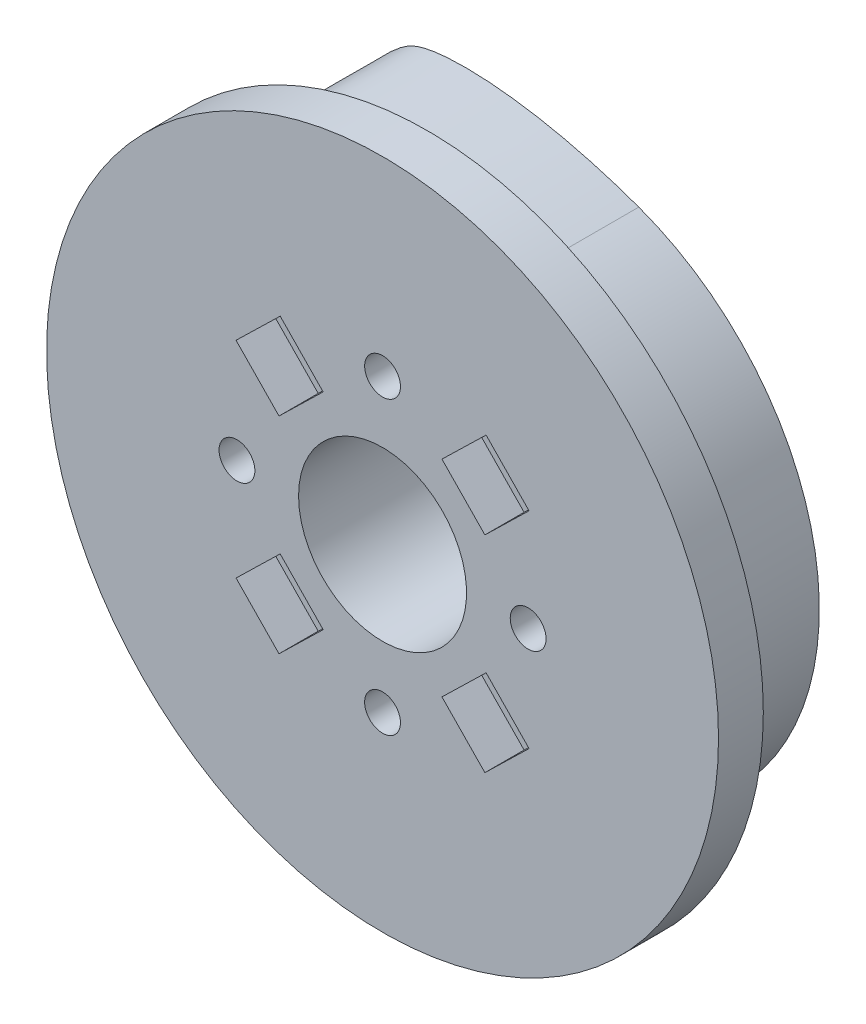
from build123d import *

# Parameters (mm, degrees)
SKETCH1_R           = 21
SKETCH1_R_2         = 2.85
SKETCH1_R_3         = 1.6
BOSS_EXTRUDE1_DEPTH = 10.5
SKETCH2_R           = 24.5
SKETCH2_R_2         = 21
BOSS_EXTRUDE3_DEPTH = 10.5
SKETCH4_R           = 30
SKETCH4_R_2         = 1.6
BOSS_EXTRUDE5_DEPTH = 4
SKETCH3_R           = 21
SKETCH3_R_2         = 1.6
BOSS_EXTRUDE4_DEPTH = 0.5
SKETCH6_W           = 5.5
SKETCH6_H           = 5.5
CUT_EXTRUDE2_DEPTH  = 3.5
SKETCH7_R           = 1.6
CUT_EXTRUDE3_DEPTH  = 46.000000133
SKETCH7_3_R         = 1.6
CUT_EXTRUDE4_DEPTH  = 3.5
SKETCH8_R           = 7.5
CUT_EXTRUDE5_DEPTH  = 46.000000133


with BuildPart() as part:
    # Sketch1 → Boss-Extrude1 (new body)
    with BuildSketch(Plane(origin=(0, 0, 0), x_dir=(0, 1, 0), z_dir=(0, 0, 1))):
        with Locations(Location((0, 0, 0), (0, 0, 90))):
            Circle(SKETCH1_R)
        with Locations((-13, 0)):
            Circle(SKETCH1_R_2, mode=Mode.SUBTRACT)
        with Locations((0, -13)):
            Circle(SKETCH1_R_2, mode=Mode.SUBTRACT)
        with Locations((13, 0)):
            Circle(SKETCH1_R_2, mode=Mode.SUBTRACT)
        with Locations((0, 13)):
            Circle(SKETCH1_R_2, mode=Mode.SUBTRACT)
        with Locations((-13, 0)):
            Circle(SKETCH1_R_2)
        with Locations(Location((-13, 0, 0), (0, 0, 90))):
            Circle(SKETCH1_R_3, mode=Mode.SUBTRACT)
        with Locations((0, 13)):
            Circle(SKETCH1_R_2)
        with Locations(Location((0, 13, 0), (0, 0, 90))):
            Circle(SKETCH1_R_3, mode=Mode.SUBTRACT)
        with Locations((13, 0)):
            Circle(SKETCH1_R_2)
        with Locations(Location((13, 0, 0), (0, 0, 90))):
            Circle(SKETCH1_R_3, mode=Mode.SUBTRACT)
        with Locations((0, -13)):
            Circle(SKETCH1_R_2)
        with Locations(Location((0, -13, 0), (0, 0, 90))):
            Circle(SKETCH1_R_3, mode=Mode.SUBTRACT)
    extrude(amount=BOSS_EXTRUDE1_DEPTH)

    # Sketch2 → Boss-Extrude3 (add)
    with BuildSketch(Plane(origin=(0, 0, 0), x_dir=(1, 0, 0), z_dir=(0, 0, -1))):
        Circle(SKETCH2_R)
        Circle(SKETCH2_R_2, mode=Mode.SUBTRACT)
        with BuildLine():
            ThreePointArc((8.379493511, -23.022469209), (-10.354147413, -22.204540782), (-23.022469209, -8.379493511))
            add(Edge.make_bspline(
                [(-23.022469209, -8.379493511), (-19.944287919, -16.836727099), (-14.510611155, -24.167819962), (-9.186383124, -26.650548266), (-0.077740076, -26.100650499), (8.379493511, -23.022469209)],
                knots=[0, 0, 0, 0, 0.45, 0.55, 1, 1, 1, 1], degree=3))
        make_face()
    extrude(amount=-BOSS_EXTRUDE3_DEPTH)

    # Sketch4 → Boss-Extrude5 (add)
    with BuildSketch(Plane.XY.offset(10.5)):
        Circle(SKETCH4_R)
        with Locations(Location((-13, 0, 0), (0, 0, 180))):
            Circle(SKETCH4_R_2, mode=Mode.SUBTRACT)
        with Locations(Location((0, 13, 0), (0, 0, 180))):
            Circle(SKETCH4_R_2, mode=Mode.SUBTRACT)
        with Locations(Location((13, 0, 0), (0, 0, 180))):
            Circle(SKETCH4_R_2, mode=Mode.SUBTRACT)
        with Locations(Location((0, -13, 0), (0, 0, 180))):
            Circle(SKETCH4_R_2, mode=Mode.SUBTRACT)
    extrude(amount=BOSS_EXTRUDE5_DEPTH)

    # Sketch3 → Boss-Extrude4 (add)
    with BuildSketch(Plane(origin=(0, 0, 0), x_dir=(1, 0, 0), z_dir=(0, 0, -1))):
        with Locations(Location((0, 0, 0), (0, 0, 180))):
            Circle(SKETCH3_R)
        with Locations(Location((-13, 0, 0), (0, 0, 180))):
            Circle(SKETCH3_R_2, mode=Mode.SUBTRACT)
        with Locations(Location((0, 13, 0), (0, 0, 180))):
            Circle(SKETCH3_R_2, mode=Mode.SUBTRACT)
        with Locations(Location((13, 0, 0), (0, 0, 180))):
            Circle(SKETCH3_R_2, mode=Mode.SUBTRACT)
        with Locations(Location((0, -13, 0), (0, 0, 180))):
            Circle(SKETCH3_R_2, mode=Mode.SUBTRACT)
    extrude(amount=BOSS_EXTRUDE4_DEPTH)

    # Sketch6 → Cut-Extrude2 (cut)
    with BuildSketch(Plane(origin=(0, 0, -0.5), x_dir=(1, 0, 0), z_dir=(0, 0, -1))):
        with Locations((13, 0)):
            Rectangle(SKETCH6_W, SKETCH6_H)
        with Locations((0, 13)):
            Rectangle(SKETCH6_W, SKETCH6_H)
        with Locations((0, -13)):
            Rectangle(SKETCH6_W, SKETCH6_H)
        with Locations((-13, 0)):
            Rectangle(SKETCH6_W, SKETCH6_H)
    extrude(amount=-CUT_EXTRUDE2_DEPTH, mode=Mode.SUBTRACT)

    # Sketch7 → Cut-Extrude3 (cut, through all)
    with BuildSketch(Plane.XY.offset(14.5)):
        with Locations((9.192388155, 9.192388155)):
            Circle(SKETCH7_R)
        with Locations((9.192388155, -9.192388155)):
            Circle(SKETCH7_R)
        with Locations((-9.192388155, -9.192388155)):
            Circle(SKETCH7_R)
        with Locations((-9.192388155, 9.192388155)):
            Circle(SKETCH7_R)
    extrude(amount=-CUT_EXTRUDE3_DEPTH, mode=Mode.SUBTRACT)

    # Sketch7_3 → Cut-Extrude4 (cut)
    with BuildSketch(Plane.XY.offset(14.5)):
        Polygon((9.245595054, 13.080678059), (5.304110209, 9.246461763), (9.139181257, 5.304098252), (13.080666102, 9.138314547), align=None)
        with Locations((9.192388155, 9.192388155)):
            Circle(SKETCH7_3_R, mode=Mode.SUBTRACT)
        Polygon((9.138314547, -13.080666102), (5.304098252, -9.139181257), (9.246461763, -5.304110209), (13.080678059, -9.245595054), align=None)
        with Locations((9.192388155, -9.192388155)):
            Circle(SKETCH7_3_R, mode=Mode.SUBTRACT)
        Polygon((-13.080666102, -9.138314547), (-9.139181257, -5.304098252), (-5.304110209, -9.246461763), (-9.245595054, -13.080678059), align=None)
        with Locations((-9.192388155, -9.192388155)):
            Circle(SKETCH7_3_R, mode=Mode.SUBTRACT)
        Polygon((-9.138314547, 13.080666102), (-5.304098252, 9.139181257), (-9.246461763, 5.304110209), (-13.080678059, 9.245595054), align=None)
        with Locations((-9.192388155, 9.192388155)):
            Circle(SKETCH7_3_R, mode=Mode.SUBTRACT)
    extrude(amount=-CUT_EXTRUDE4_DEPTH, mode=Mode.SUBTRACT)

    # Sketch8 → Cut-Extrude5 (cut, through all)
    with BuildSketch(Plane(origin=(0, 0, -0.5), x_dir=(1, 0, 0), z_dir=(0, 0, -1))):
        with Locations(Location((0, 0, 0), (0, 0, 180))):
            Circle(SKETCH8_R)
    extrude(amount=-CUT_EXTRUDE5_DEPTH, mode=Mode.SUBTRACT)


solid = part.part
